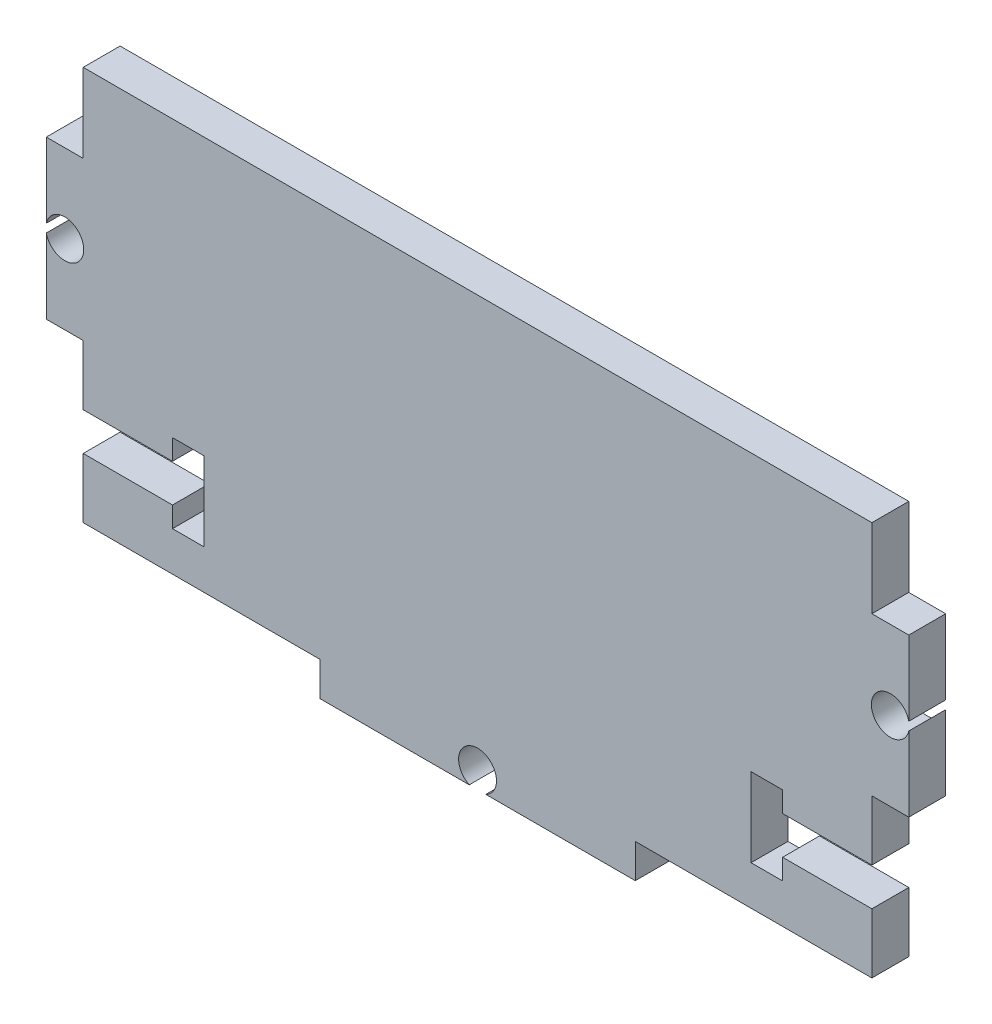
from build123d import *

# Parameters (mm, degrees)
SKETCH1_W           = 2.9718
SKETCH1_H           = 12.7
SKETCH1_W_2         = 63.5
SKETCH1_H_2         = 31.75
SKETCH1_W_3         = 25.4
SKETCH1_H_3         = 2.739734253
BOSS_EXTRUDE1_DEPTH = 2.9718
CUT_EXTRUDE1_DEPTH  = 3.9718


with BuildPart() as part:
    # Sketch1 → Boss-Extrude1 (new body)
    with BuildSketch(Plane.XY):
        with Locations((-33.2359, 3.175)):
            Rectangle(SKETCH1_W, SKETCH1_H)
        Rectangle(SKETCH1_W_2, SKETCH1_H_2)
        with Locations((33.2359, 3.175)):
            Rectangle(SKETCH1_W, SKETCH1_H)
        with Locations((0, -17.244867127)):
            Rectangle(SKETCH1_W_3, SKETCH1_H_3)
    extrude(amount=BOSS_EXTRUDE1_DEPTH)

    # Sketch2 → Cut-Extrude1 (cut, through all)
    with BuildSketch(Plane(origin=(0, 0, 0), x_dir=(-1, 0, 0), z_dir=(0, 0, -1))):
        with BuildLine():
            ThreePointArc((34.7218, 2.836359793), (34.750345047, 3.00461162), (34.7599, 3.175))
            ThreePointArc((34.7599, 3.175), (34.750345047, 3.34538838), (34.7218, 3.513640207))
            Line((34.7218, 3.513640207), (34.7218, 2.836359793))
        make_face()
        with BuildLine():
            Line((34.7218, 2.836359793), (34.7218, 3.513640207))
            ThreePointArc((34.7218, 3.513640207), (31.7119, 3.175), (34.7218, 2.836359793))
        make_face()
        with BuildLine():
            ThreePointArc((-34.7218, 2.836359793), (-33.06551162, 1.660554953), (-31.7119, 3.175))
            ThreePointArc((-31.7119, 3.175), (-33.06551162, 4.689445047), (-34.7218, 3.513640207))
            Line((-34.7218, 3.513640207), (-34.7218, 2.836359793))
        make_face()
        with BuildLine():
            Line((-34.7218, 2.836359793), (-34.7218, 3.513640207))
            ThreePointArc((-34.7218, 3.513640207), (-34.7599, 3.175), (-34.7218, 2.836359793))
        make_face()
        Polygon((-31.75, -8.001), (-31.75, -11.049), (-24.5618, -11.049), (-24.5618, -12.7), (-22.0218, -12.7), (-22.0218, -6.35), (-24.5618, -6.35), (-24.5618, -8.001), align=None)
        with BuildLine():
            ThreePointArc((0.667862303, -18.614734253), (1.29236182, -18.052565663), (1.524, -17.244867127))
            ThreePointArc((1.524, -17.244867127), (-0.807698536, -15.952505306), (-0.667862303, -18.614734253))
            Line((-0.667862303, -18.614734253), (0.667862303, -18.614734253))
        make_face()
        with BuildLine():
            Line((0.667862303, -18.614734253), (-0.667862303, -18.614734253))
            ThreePointArc((-0.667862303, -18.614734253), (0, -18.768867127), (0.667862303, -18.614734253))
        make_face()
        Polygon((31.75, -11.049), (24.5618, -11.049), (24.5618, -12.7), (22.0218, -12.7), (22.0218, -6.35), (24.5618, -6.35), (24.5618, -8.001), (31.75, -8.001), align=None)
    extrude(amount=-CUT_EXTRUDE1_DEPTH, mode=Mode.SUBTRACT)


solid = part.part
